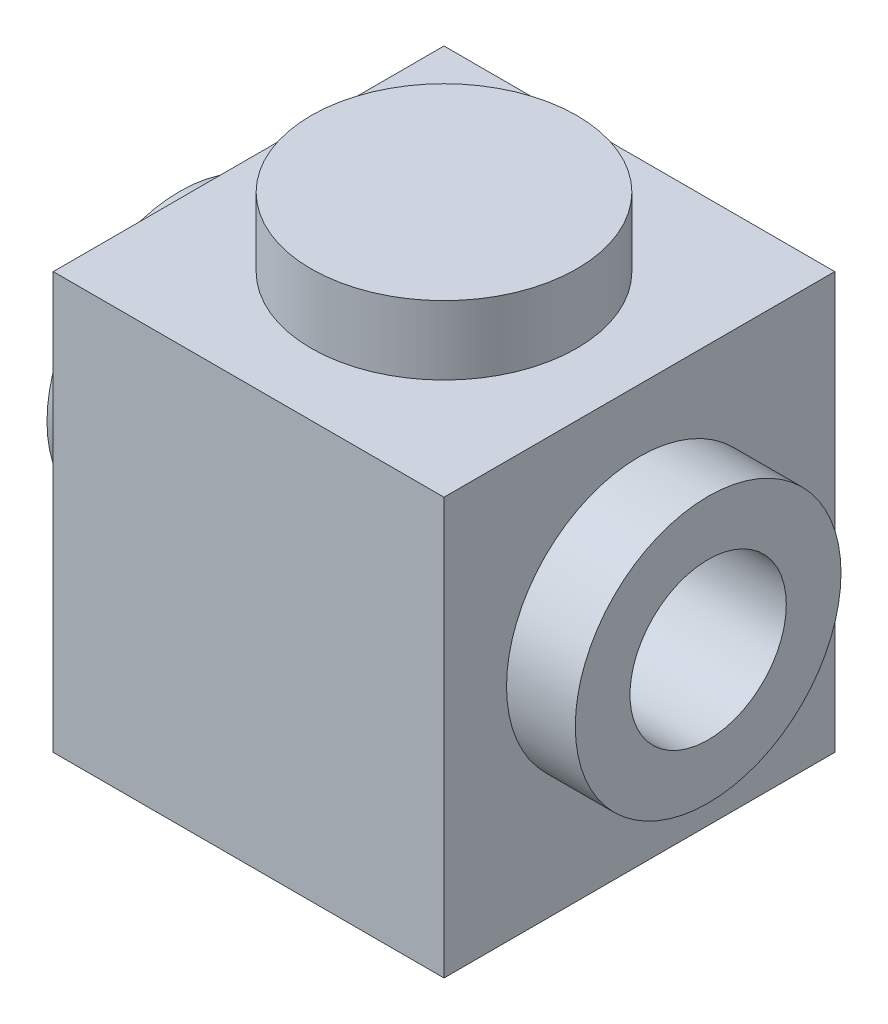
from build123d import *

# Parameters (mm, degrees)
SKETCH1_W           = 7.9375
SKETCH1_H           = 7.9375
BOSS_EXTRUDE1_DEPTH = 4.2291
SKETCH2_W           = 5.3975
SKETCH2_H           = 5.3975
CUT_EXTRUDE1_DEPTH  = 7.1882
SKETCH3_R           = 2.69875
BOSS_EXTRUDE2_DEPTH = 1.397
SKETCH5_R           = 2.69875
BOSS_EXTRUDE4_DEPTH = 1.397
SKETCH6_R           = 1.5875
CUT_EXTRUDE2_DEPTH  = 11.7315


with BuildPart() as part:
    # Sketch1 → Boss-Extrude1 (new body, symmetric)
    with BuildSketch(Plane(origin=(0, 0, 0), x_dir=(1, 0, 0), z_dir=(0, 1, 0))):
        Rectangle(SKETCH1_W, SKETCH1_H)
    extrude(amount=BOSS_EXTRUDE1_DEPTH, both=True)

    # Sketch2 → Cut-Extrude1 (cut)
    with BuildSketch(Plane.XZ.offset(4.2291)):
        Rectangle(SKETCH2_W, SKETCH2_H)
    extrude(amount=-CUT_EXTRUDE1_DEPTH, mode=Mode.SUBTRACT)

    # Sketch3 → Boss-Extrude2 (add)
    with BuildSketch(Plane(origin=(0, 4.2291, 0), x_dir=(1, 0, 0), z_dir=(0, 1, 0))):
        Circle(SKETCH3_R)
    extrude(amount=BOSS_EXTRUDE2_DEPTH)

    # Sketch5 → Boss-Extrude4 (add)
    with BuildSketch(Plane(origin=(3.96875, 0, 0), x_dir=(0, 0, -1), z_dir=(1, 0, 0))):
        with Locations((0, 0.26035)):
            Circle(SKETCH5_R)
    boss_extrude4 = extrude(amount=BOSS_EXTRUDE4_DEPTH)

    # Mirror1: Boss-Extrude4 across plane
    add(boss_extrude4.mirror(Plane(origin=(0, 0, 0), x_dir=(0, 0, 1), z_dir=(1, 0, 0))))

    # Sketch6 → Cut-Extrude2 (cut, through all)
    with BuildSketch(Plane(origin=(5.36575, 0, 0), x_dir=(0, 0, -1), z_dir=(1, 0, 0))):
        with Locations((0, 0.26035)):
            Circle(SKETCH6_R)
    extrude(amount=-CUT_EXTRUDE2_DEPTH, mode=Mode.SUBTRACT)


solid = part.part
